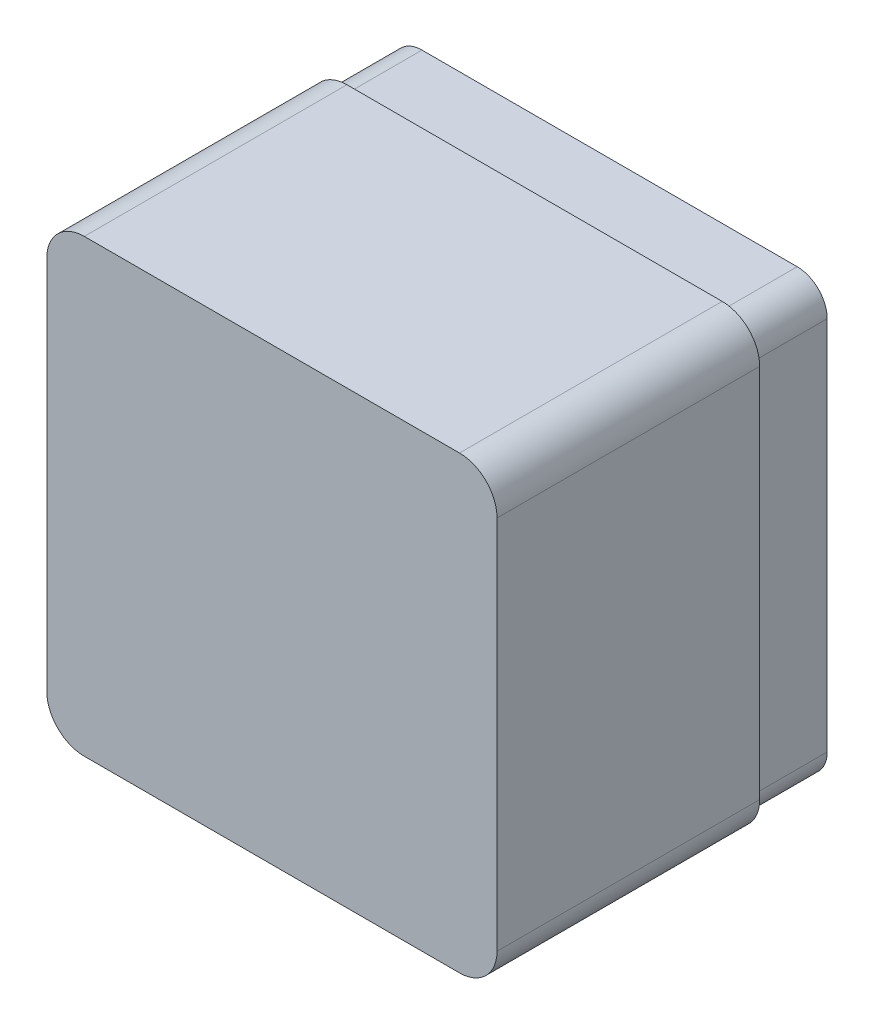
from build123d import *

# Parameters (mm, degrees)
SKETCH2_W           = 120
SKETCH2_H           = 120
BOSS_EXTRUDE1_DEPTH = 90
FILLET1_R           = 10
SHELL2_T            = -4
SKETCH4_OUTSIDE_W   = 160.418
SKETCH4_OUTSIDE_H   = 160.418
CUT_EXTRUDE5_DEPTH  = 20


with BuildPart() as part:
    # Sketch2 → Boss-Extrude1 (new body)
    with BuildSketch(Plane.XY):
        with Locations((60, 60)):
            Rectangle(SKETCH2_W, SKETCH2_H)
    extrude(amount=BOSS_EXTRUDE1_DEPTH)

    # Fillet1
    fillet1_edges = [part.edges().sort_by_distance(p)[0] for p in [
        (0, 120, 45),
        (120, 120, 45),
        (120, 0, 45),
        (0, 0, 45),
    ]]
    fillet(fillet1_edges, radius=FILLET1_R)

    # Shell2
    shell2_openings = [part.faces().sort_by_distance(p)[0] for p in [
        (60, 60, 0),
    ]]
    offset(amount=SHELL2_T, openings=shell2_openings, kind=Kind.INTERSECTION)

    # Sketch4 outside → Cut-Extrude5 (cut)
    with BuildSketch(Plane(origin=(0, 0, 0), x_dir=(-1, 0, 0), z_dir=(0, 0, -1))):
        with Locations((-60, 60)):
            Rectangle(SKETCH4_OUTSIDE_W, SKETCH4_OUTSIDE_H)
        with BuildLine():
            Line((-110, 2), (-10, 2))
            ThreePointArc((-10, 2), (-4.343145751, 4.343145751), (-2, 10))
            Line((-2, 10), (-2, 110))
            ThreePointArc((-2, 110), (-4.343145751, 115.656854249), (-10, 118))
            Line((-10, 118), (-110, 118))
            ThreePointArc((-110, 118), (-115.656854249, 115.656854249), (-118, 110))
            Line((-118, 110), (-118, 10))
            ThreePointArc((-118, 10), (-115.656854249, 4.343145751), (-110, 2))
        make_face(mode=Mode.SUBTRACT)
    extrude(amount=-CUT_EXTRUDE5_DEPTH, mode=Mode.SUBTRACT)


solid = part.part
